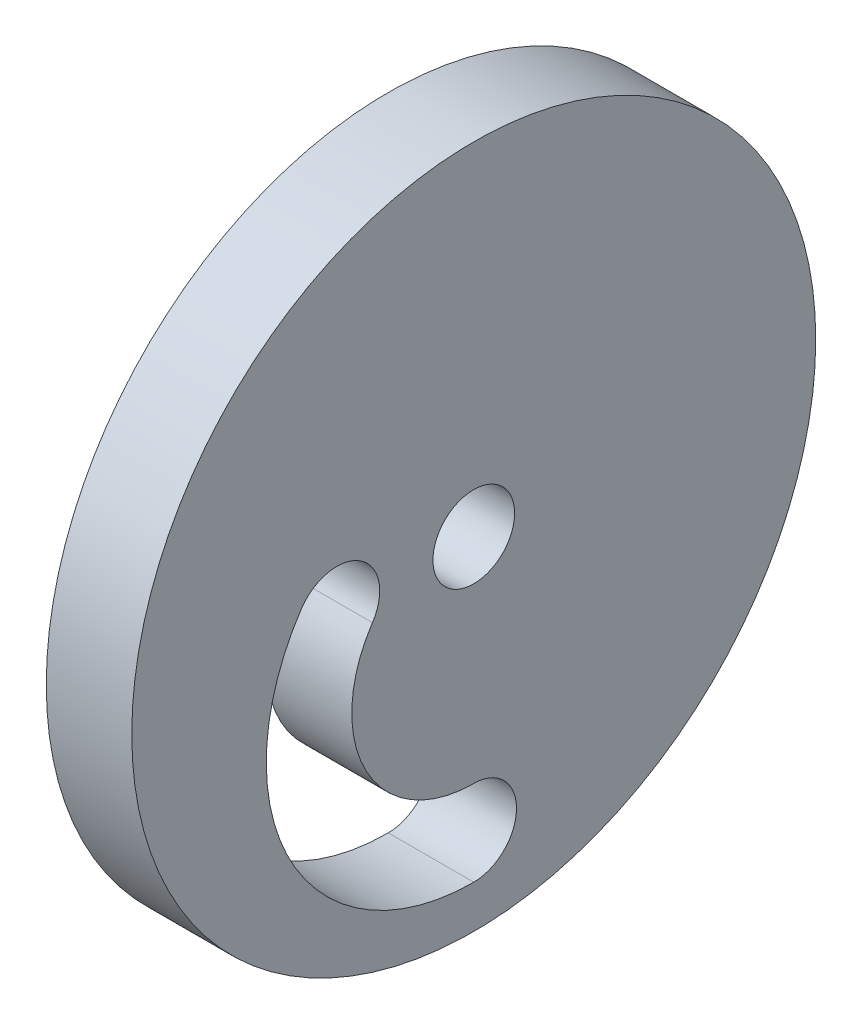
from build123d import *

# Parameters (mm, degrees)
SKETCH1_R           = 25.4
SKETCH1_R_2         = 3.031432634
BOSS_EXTRUDE1_DEPTH = 6.35


with BuildPart() as part:
    # Sketch1 → Boss-Extrude1 (new body)
    with BuildSketch(Plane(origin=(0, 0, 0), x_dir=(0, 0, -1), z_dir=(1, 0, 0))):
        Circle(SKETCH1_R)
        Circle(SKETCH1_R_2, mode=Mode.SUBTRACT)
        with BuildLine():
            ThreePointArc((-12.796678201, 1.768771626), (-13.596470588, -14.067117647), (0, -22.225))
            ThreePointArc((0, -22.225), (3.175, -19.05), (0, -15.875))
            ThreePointArc((0, -15.875), (-7.993529412, -11.078882353), (-7.523321799, -1.768771626))
            ThreePointArc((-7.523321799, -1.768771626), (-8.391228374, 2.636678201), (-12.796678201, 1.768771626))
        make_face(mode=Mode.SUBTRACT)
    extrude(amount=BOSS_EXTRUDE1_DEPTH)


solid = part.part
